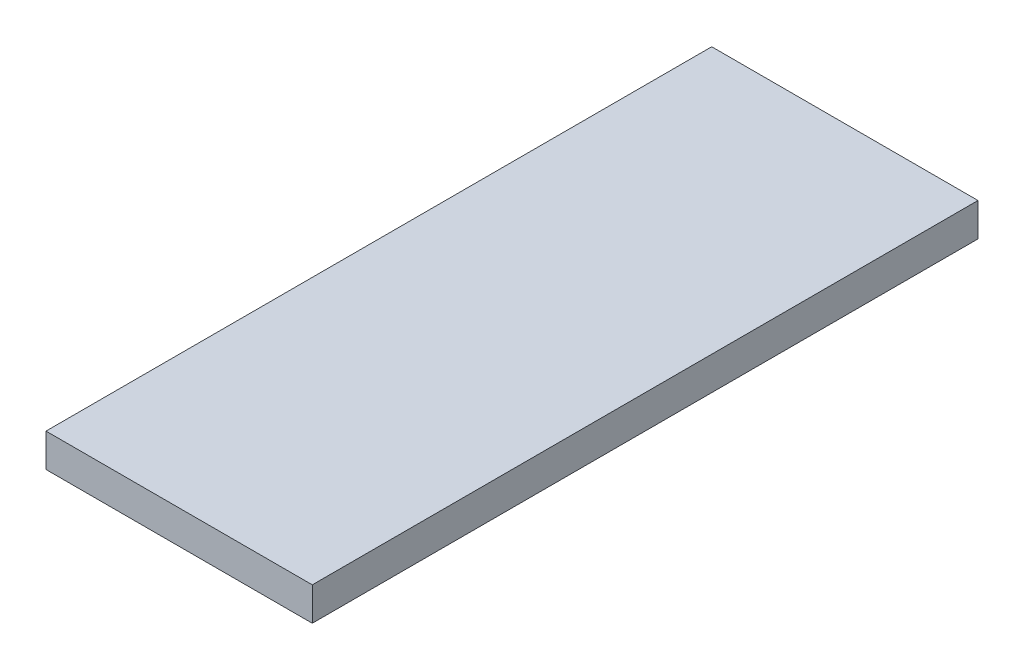
from build123d import *

# Parameters (mm, degrees)
SKETCH_1_W      = 40
SKETCH_1_H      = 100
EXTRUDE_1_DEPTH = 5


with BuildPart() as part:
    # Эскиз1 → Бобышка-Вытянуть1 (new body)
    with BuildSketch(Plane(origin=(0, 0, 0), x_dir=(1, 0, 0), z_dir=(0, 1, 0))):
        with Locations((20, 50)):
            Rectangle(SKETCH_1_W, SKETCH_1_H)
    extrude(amount=EXTRUDE_1_DEPTH)


solid = part.part
